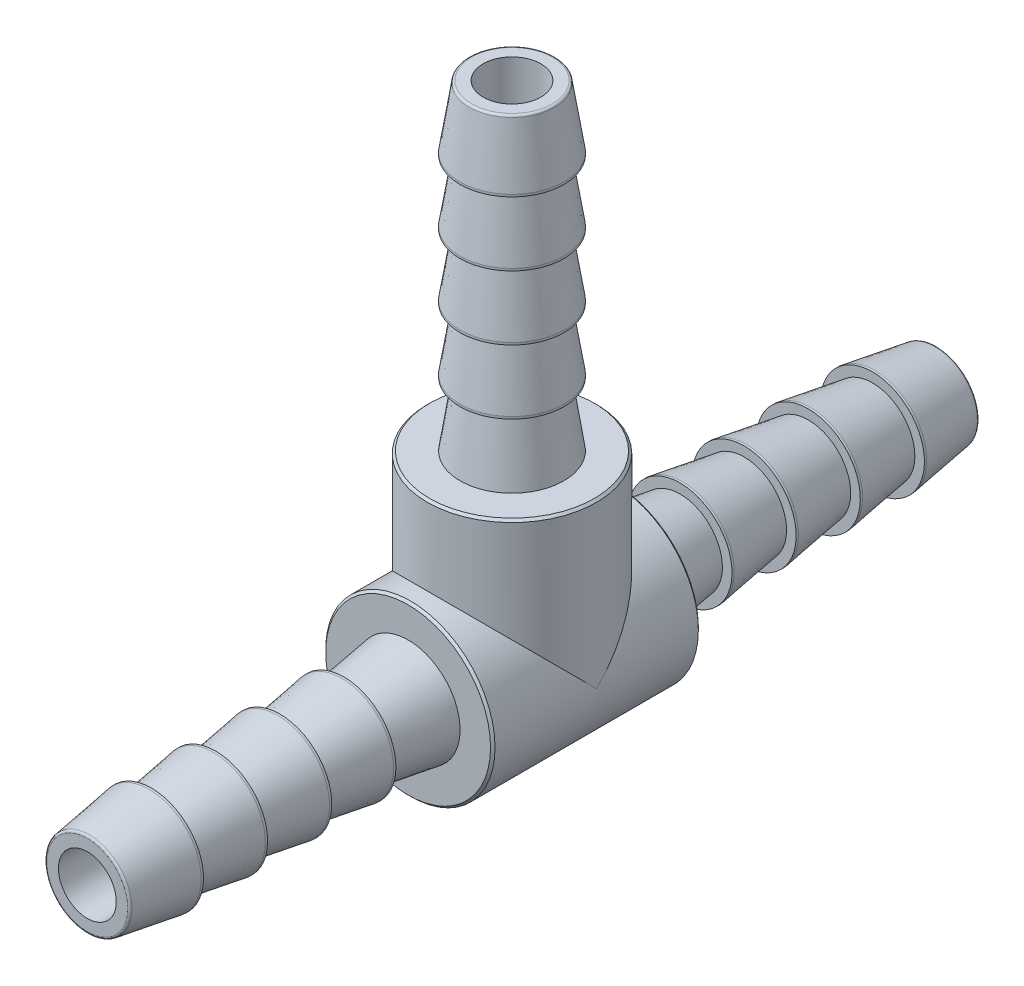
from build123d import *

# Parameters (mm, degrees)
SKETCH2_W       = 47.752
SKETCH2_H       = 4.7625
LPATTERN1_COUNT = 4
LPATTERN1_PITCH = 3.6068
SKETCH6_W       = 4.7625
SKETCH6_H       = 27.2415
LPATTERN2_COUNT = 4
LPATTERN2_PITCH = 3.6068
SKETCH5_W       = 57.104130169
SKETCH5_H       = 1.6256
SKETCH9_W       = 1.6256
SKETCH9_H       = 27.2415
CHAMFER1_SIZE   = 0.127
FILLET1_R       = 0.127


with BuildPart() as part:
    # Sketch2 → Revolve1 (revolve)
    with BuildSketch(Plane(origin=(0, 0, 0), x_dir=(0, 0, -1), z_dir=(1, 0, 0)), mode=Mode.PRIVATE) as revolve1_sk:
        with Locations((0, 2.38125)):
            Rectangle(SKETCH2_W, SKETCH2_H)
    revolve(revolve1_sk.sketch.rotate(Axis((0, 0, 23.876), (0, 0, -1)), 90), axis=Axis((0, 0, 23.876), (0, 0, -1)))

    # Sketch3 → Cut-Revolve1 (revolve, cut)
    with BuildSketch(Plane(origin=(0, 0, 0), x_dir=(0, 0, -1), z_dir=(1, 0, 0)), mode=Mode.PRIVATE) as cut_revolve1_sk:
        Polygon((-23.876, 4.7625), (-23.876, 2.38125), (-9.4488, 2.38125), (-5.842, 2.921), (-5.842, 4.7625), align=None)
    cut_revolve1 = revolve(cut_revolve1_sk.sketch.rotate(Axis((0, 0, 23.876), (0, 0, -1)), 90), axis=Axis((0, 0, 23.876), (0, 0, -1)), mode=Mode.SUBTRACT)

    # Sketch4 → Revolve2 (revolve)
    with BuildSketch(Plane(origin=(0, 0, 0), x_dir=(0, 0, -1), z_dir=(1, 0, 0))):
        Polygon((-20.2692, 2.921), (-20.3962, 2.921), (-23.876, 2.38125), (-20.2692, 2.38125), align=None)
    revolve2 = revolve(axis=Axis((0, 0, 5.842), (0, 0, 1)))

    # LPattern1: Revolve2 ×4
    with Locations(*[(0, 0, -i * LPATTERN1_PITCH) for i in range(1, LPATTERN1_COUNT)]):
        add(revolve2)

    # Mirror1: Cut-Revolve1, Revolve2 across plane
    add(cut_revolve1.mirror(Plane.XY), mode=Mode.SUBTRACT)
    add(revolve2.mirror(Plane.XY))

    # Mirror1 copy 1 sketch → Mirror1 copy 1 (revolve)
    with BuildSketch(Plane(origin=(0, 0, 3.6068), x_dir=(0, 0, 1), z_dir=(1, 0, 0))):
        Polygon((-20.2692, -2.921), (-20.3962, -2.921), (-23.876, -2.38125), (-20.2692, -2.38125), align=None)
    revolve(axis=Axis((0, 0, -2.2352), (0, 0, 1)))

    # Mirror1 copy 2 sketch → Mirror1 copy 2 (revolve)
    with BuildSketch(Plane(origin=(0, 0, 7.2136), x_dir=(0, 0, 1), z_dir=(1, 0, 0))):
        Polygon((-20.2692, -2.921), (-20.3962, -2.921), (-23.876, -2.38125), (-20.2692, -2.38125), align=None)
    revolve(axis=Axis((0, 0, 1.3716), (0, 0, 1)))

    # Mirror1 copy 3 sketch → Mirror1 copy 3 (revolve)
    with BuildSketch(Plane(origin=(0, 0, 10.8204), x_dir=(0, 0, 1), z_dir=(1, 0, 0))):
        Polygon((-20.2692, -2.921), (-20.3962, -2.921), (-23.876, -2.38125), (-20.2692, -2.38125), align=None)
    revolve(axis=Axis((0, 0, 4.9784), (0, 0, 1)))

    # Sketch6 → Revolve3 (revolve)
    with BuildSketch(Plane(origin=(0, 0, 0), x_dir=(0, 0, -1), z_dir=(1, 0, 0)), mode=Mode.PRIVATE) as revolve3_sk:
        with Locations((-2.38125, 13.62075)):
            Rectangle(SKETCH6_W, SKETCH6_H)
    revolve(revolve3_sk.sketch.rotate(Axis((0, 0, 0), (0, 1, 0)), 180), axis=Axis((0, 0, 0), (0, 1, 0)))

    # Sketch7 → Cut-Revolve3 (revolve, cut)
    with BuildSketch(Plane(origin=(0, 0, 0), x_dir=(0, 0, -1), z_dir=(1, 0, 0)), mode=Mode.PRIVATE) as cut_revolve3_sk:
        Polygon((-2.921, 9.2075), (-2.38125, 12.8143), (-2.38125, 27.2415), (-4.7625, 27.2415), (-4.7625, 9.2075), align=None)
    revolve(cut_revolve3_sk.sketch.rotate(Axis((0, 0, 0), (0, 1, 0)), 180), axis=Axis((0, 0, 0), (0, 1, 0)), mode=Mode.SUBTRACT)

    # Sketch8 → Revolve4 (revolve)
    with BuildSketch(Plane(origin=(0, 0, 0), x_dir=(0, 0, -1), z_dir=(1, 0, 0)), mode=Mode.PRIVATE) as revolve4_sk:
        Polygon((-2.38125, 27.2415), (-2.921, 23.7617), (-2.921, 23.6347), (-2.38125, 23.6347), align=None)
    revolve4 = revolve(revolve4_sk.sketch.rotate(Axis((0, 27.2415, 0), (0, -1, 0)), 180), axis=Axis((0, 27.2415, 0), (0, -1, 0)))

    # LPattern2: Revolve4 ×4
    with Locations(*[(0, -i * LPATTERN2_PITCH, 0) for i in range(1, LPATTERN2_COUNT)]):
        add(revolve4)

    # Sketch5 → Cut-Revolve2 (revolve, cut)
    with BuildSketch(Plane(origin=(0, 0, 0), x_dir=(0, 0, -1), z_dir=(1, 0, 0))):
        with Locations((4.676065085, 0.8128)):
            Rectangle(SKETCH5_W, SKETCH5_H)
    revolve(axis=Axis((0, 0, 23.876), (0, 0, -1)), mode=Mode.SUBTRACT)

    # Sketch9 → Cut-Revolve4 (revolve, cut)
    with BuildSketch(Plane(origin=(0, 0, 0), x_dir=(0, 0, -1), z_dir=(1, 0, 0))):
        with Locations((-0.8128, 13.62075)):
            Rectangle(SKETCH9_W, SKETCH9_H)
    revolve(axis=Axis((0, 27.2415, 0), (0, -1, 0)), mode=Mode.SUBTRACT)

    # Chamfer1
    chamfer1_edges = [part.edges().sort_by_distance(p)[0] for p in [
        (-4.7625, 0, -5.842),
        (0, 9.2075, 4.7625),
        (-4.7625, 0, 5.842),
    ]]
    chamfer(chamfer1_edges, length=CHAMFER1_SIZE)

    # Fillet1
    fillet1_edges = [part.edges().sort_by_distance(p)[0] for p in [
        (0, -2.38125, 23.876),
        (0, -2.38125, -23.876),
        (0, 27.2415, 2.38125),
    ]]
    fillet(fillet1_edges, radius=FILLET1_R)


solid = part.part
